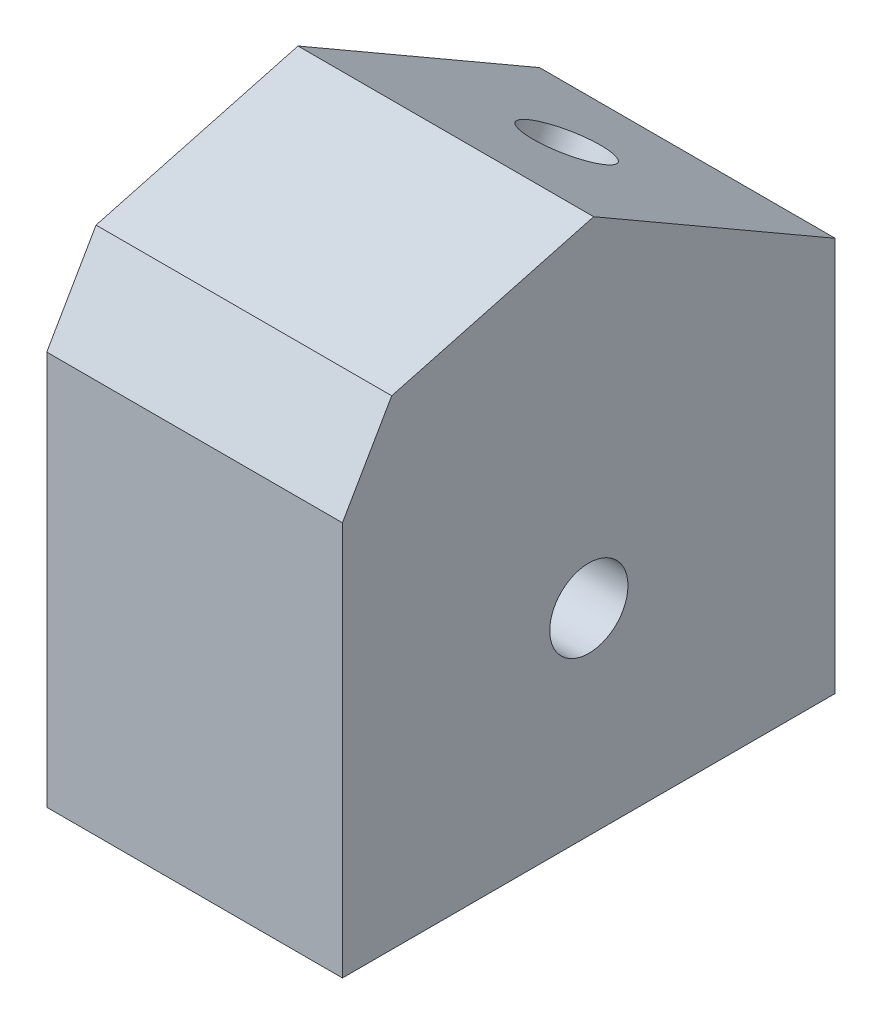
from build123d import *

# Parameters (mm, degrees)
ESBO_O1_R                = 3.97
RESSALTO_EXTRUS_O1_DEPTH = 15
ESBO_O3_R                = 3.97
CORTE_EXTRUS_O2_DEPTH    = 25
CHANFRO1_SIZE            = 15
ESBO_O4_R                = 3.97
CORTE_EXTRUS_O3_DEPTH    = 15


with BuildPart() as part:
    # Esboço1 → Ressalto-extrusão1 (new body, symmetric)
    with BuildSketch(Plane(origin=(0, 0, 0), x_dir=(0, 0, -1), z_dir=(1, 0, 0))):
        Polygon((25, -20), (-25, -20), (-25, 20), (-12.5, 41.650635095), (25, 20), align=None)
        Circle(ESBO_O1_R, mode=Mode.SUBTRACT)
    extrude(amount=RESSALTO_EXTRUS_O1_DEPTH, both=True)

    # Esboço3 → Corte-extrusão2 (cut)
    with BuildSketch(Plane(origin=(0, 0, -25), x_dir=(-1, 0, 0), z_dir=(0, 0, -1))):
        Circle(ESBO_O3_R)
    extrude(amount=-CORTE_EXTRUS_O2_DEPTH, mode=Mode.SUBTRACT)

    # Chanfro1
    chanfro1_edges = [part.edges().sort_by_distance(p)[0] for p in [
        (0, 41.650635095, 12.5),
    ]]
    chamfer(chanfro1_edges, length=CHANFRO1_SIZE)

    # Esboço4 → Corte-extrusão3 (cut)
    with BuildSketch(Plane(origin=(0, 25.825317547, -14.910254038), x_dir=(1, 0, 0), z_dir=(0, 0.866025404, -0.5))):
        with Locations((0, -2.5)):
            Circle(ESBO_O4_R)
    extrude(amount=-CORTE_EXTRUS_O3_DEPTH, mode=Mode.SUBTRACT)


solid = part.part
